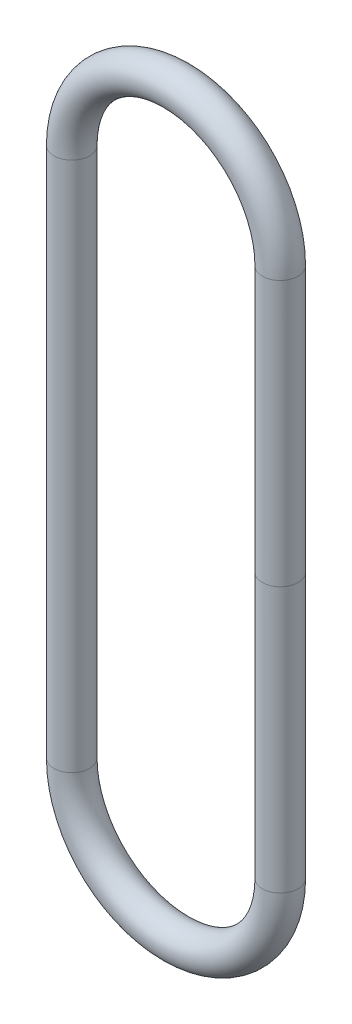
from build123d import *

# Parameters (mm, degrees)
SKETCH2_R = 0.889


with BuildPart() as part:
    # -019 O-Ring: sweep along a path in Sketch1
    with BuildLine(Plane.XY) as f_019_o_ring_path:
        Line((-4.2895, -13.175), (-4.2895, 13.175))
        ThreePointArc((-4.2895, 13.175), (0, 17.4645), (4.2895, 13.175))
        Line((4.2895, 13.175), (4.2895, -13.175))
        ThreePointArc((4.2895, -13.175), (0, -17.4645), (-4.2895, -13.175))
    # Sketch2 → -019 O-Ring (sweep)
    with BuildSketch(Plane(origin=(0, 0, 0), x_dir=(1, 0, 0), z_dir=(0, 1, 0))):
        with Locations((5.1785, 0)):
            Circle(SKETCH2_R)
    sweep(path=f_019_o_ring_path.line)


solid = part.part
